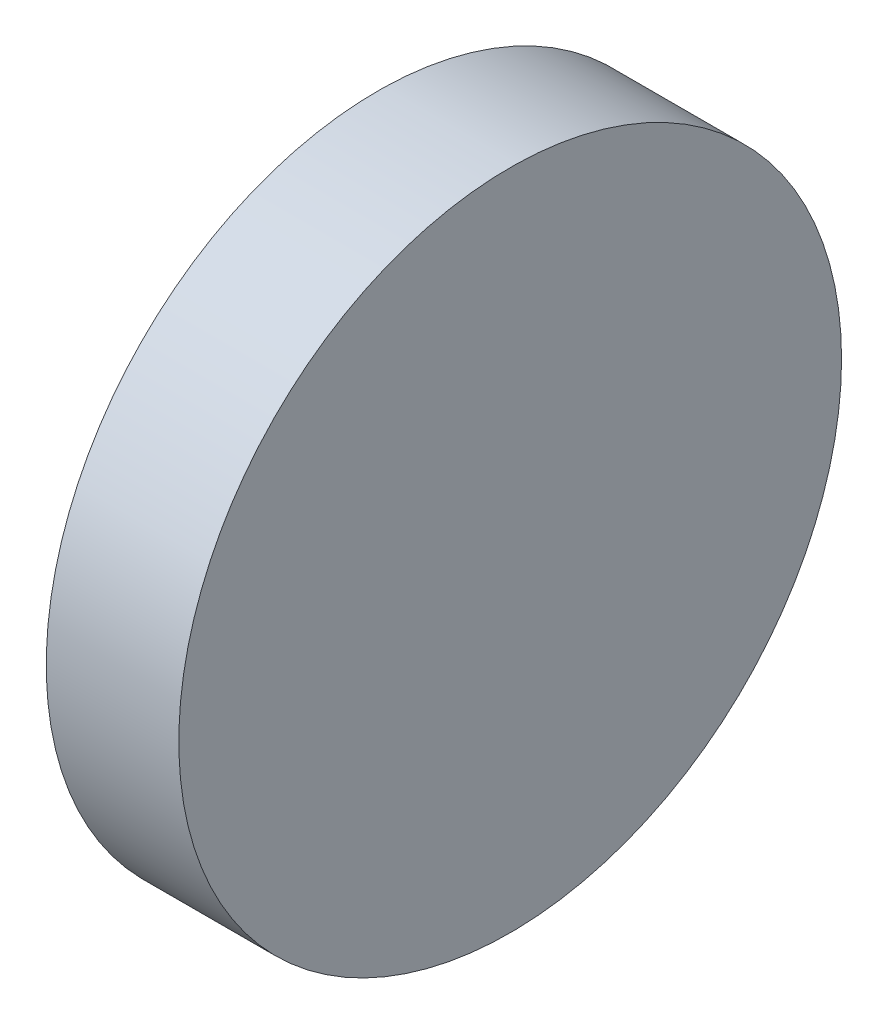
from build123d import *

# Parameters (mm, degrees)
SKETCH1_R           = 31.75
BOSS_EXTRUDE1_DEPTH = 12.7


with BuildPart() as part:
    # Sketch1 → Boss-Extrude1 (new body)
    with BuildSketch(Plane(origin=(0, 0, 0), x_dir=(0, 0, -1), z_dir=(1, 0, 0))):
        Circle(SKETCH1_R)
    extrude(amount=BOSS_EXTRUDE1_DEPTH)


solid = part.part
